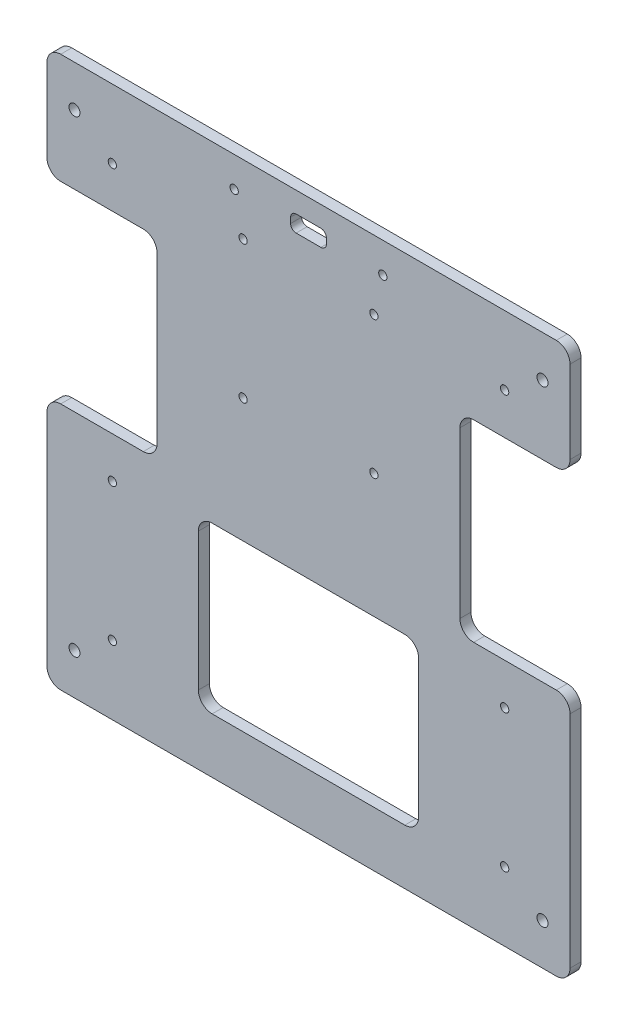
from build123d import *

# Parameters (mm, degrees)
BOSS_EXTRUDE1_DEPTH = 4
CUT_EXTRUDE1_DEPTH  = 4
SKETCH3_R           = 2
SKETCH3_R_2         = 1.5
CUT_EXTRUDE2_DEPTH  = 10
SKETCH4_R           = 1.5
CUT_EXTRUDE3_DEPTH  = 10


with BuildPart() as part:
    # Sketch1 → Boss-Extrude1 (new body)
    with BuildSketch(Plane.XY):
        with BuildLine():
            Line((-95, -115), (-95, -195))
            ThreePointArc((-95, -195), (-93.535533906, -198.535533906), (-90, -200))
            Line((-90, -200), (90, -200))
            ThreePointArc((90, -200), (93.535533906, -198.535533906), (95, -195))
            Line((95, -195), (95, -115))
            ThreePointArc((95, -115), (93.535533906, -111.464466094), (90, -110))
            Line((90, -110), (60, -110))
            ThreePointArc((60, -110), (56.464466094, -108.535533906), (55, -105))
            Line((55, -105), (55, -45))
            ThreePointArc((55, -45), (56.464466094, -41.464466094), (60, -40))
            Line((60, -40), (90, -40))
            ThreePointArc((90, -40), (93.535533906, -38.535533906), (95, -35))
            Line((95, -35), (95, -5))
            ThreePointArc((95, -5), (93.535533906, -1.464466094), (90, 0))
            Line((90, 0), (-90, 0))
            ThreePointArc((-90, 0), (-93.535533906, -1.464466094), (-95, -5))
            Line((-95, -5), (-95, -35))
            ThreePointArc((-95, -35), (-93.535533906, -38.535533906), (-90, -40))
            Line((-90, -40), (-60, -40))
            ThreePointArc((-60, -40), (-56.464466094, -41.464466094), (-55, -45))
            Line((-55, -45), (-55, -105))
            ThreePointArc((-55, -105), (-56.464466094, -108.535533906), (-60, -110))
            Line((-60, -110), (-90, -110))
            ThreePointArc((-90, -110), (-93.535533906, -111.464466094), (-95, -115))
        make_face()
    extrude(amount=BOSS_EXTRUDE1_DEPTH)

    # Sketch2 → Cut-Extrude1 (cut)
    with BuildSketch(Plane.XY.offset(4)):
        with BuildLine():
            Line((-35, -120), (35, -120))
            ThreePointArc((35, -120), (38.535533906, -121.464466094), (40, -125))
            Line((40, -125), (40, -175))
            ThreePointArc((40, -175), (38.535533906, -178.535533906), (35, -180))
            Line((35, -180), (-35, -180))
            ThreePointArc((-35, -180), (-38.535533906, -178.535533906), (-40, -175))
            Line((-40, -175), (-40, -125))
            ThreePointArc((-40, -125), (-38.535533906, -121.464466094), (-35, -120))
        make_face()
    extrude(amount=-CUT_EXTRUDE1_DEPTH, mode=Mode.SUBTRACT)

    # Sketch3 → Cut-Extrude2 (cut)
    with BuildSketch(Plane.XY.offset(4)):
        with Locations((-85, -15)):
            Circle(SKETCH3_R)
        with Locations((-85, -185)):
            Circle(SKETCH3_R)
        with Locations((85, -185)):
            Circle(SKETCH3_R)
        with Locations((85, -15)):
            Circle(SKETCH3_R)
        with Locations((-27, -11)):
            Circle(SKETCH3_R_2)
        with Locations((27, -11)):
            Circle(SKETCH3_R_2)
        with BuildLine():
            Line((-4.5, -7.5), (4.5, -7.5))
            ThreePointArc((4.5, -7.5), (5.914213562, -8.085786438), (6.5, -9.5))
            Line((6.5, -9.5), (6.5, -11.5))
            ThreePointArc((6.5, -11.5), (5.914213562, -12.914213562), (4.5, -13.5))
            Line((4.5, -13.5), (-4.5, -13.5))
            ThreePointArc((-4.5, -13.5), (-5.914213562, -12.914213562), (-6.5, -11.5))
            Line((-6.5, -11.5), (-6.5, -9.5))
            ThreePointArc((-6.5, -9.5), (-5.914213562, -8.085786438), (-4.5, -7.5))
        make_face()
    extrude(amount=-CUT_EXTRUDE2_DEPTH, mode=Mode.SUBTRACT)

    # Sketch4 → Cut-Extrude3 (cut)
    with BuildSketch(Plane.XY.offset(4)):
        with Locations((-71.25, -25)):
            Circle(SKETCH4_R)
        with Locations((-71.25, -75)):
            Circle(SKETCH4_R)
        with Locations((-71.25, -175)):
            Circle(SKETCH4_R)
        with Locations((-71.25, -125)):
            Circle(SKETCH4_R)
        with Locations((-23.75, -125)):
            Circle(SKETCH4_R)
        with Locations((-23.75, -175)):
            Circle(SKETCH4_R)
        with Locations((-23.75, -75)):
            Circle(SKETCH4_R)
        with Locations((-23.75, -25)):
            Circle(SKETCH4_R)
        with Locations((23.75, -25)):
            Circle(SKETCH4_R)
        with Locations((23.75, -75)):
            Circle(SKETCH4_R)
        with Locations((23.75, -175)):
            Circle(SKETCH4_R)
        with Locations((23.75, -125)):
            Circle(SKETCH4_R)
        with Locations((71.25, -125)):
            Circle(SKETCH4_R)
        with Locations((71.25, -175)):
            Circle(SKETCH4_R)
        with Locations((71.25, -75)):
            Circle(SKETCH4_R)
        with Locations((71.25, -25)):
            Circle(SKETCH4_R)
    extrude(amount=-CUT_EXTRUDE3_DEPTH, mode=Mode.SUBTRACT)


solid = part.part
